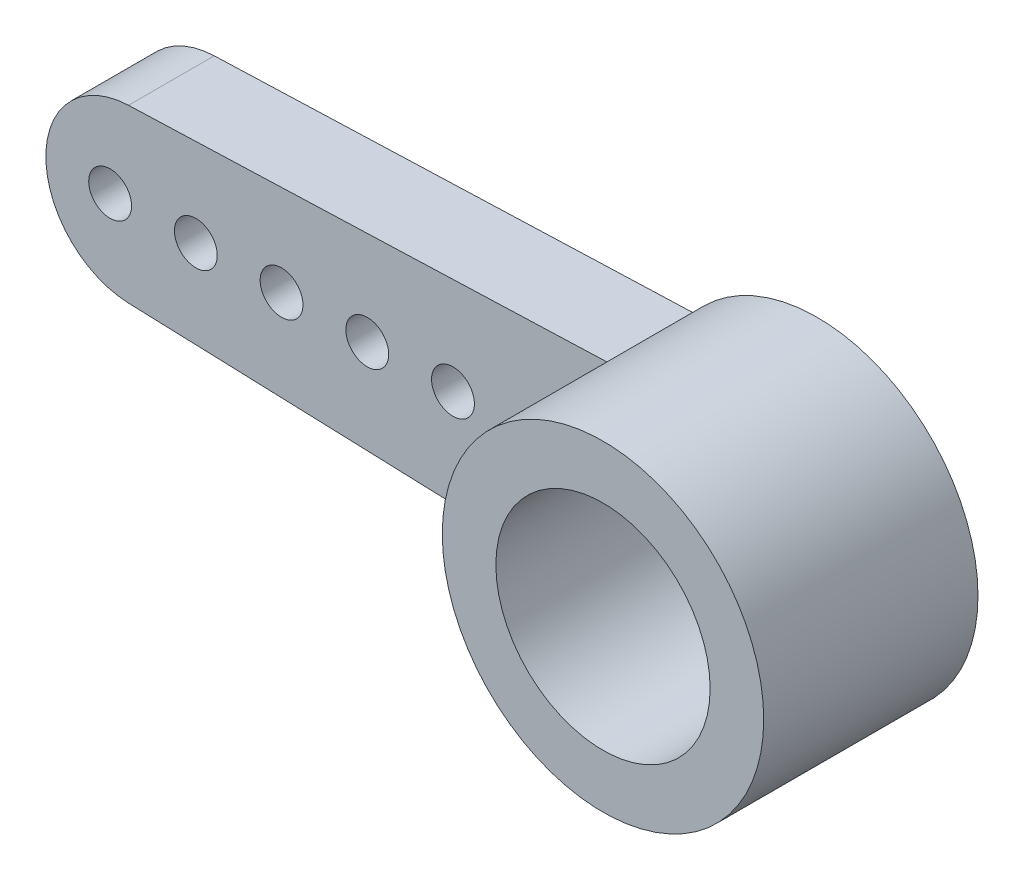
from build123d import *

# Parameters (mm, degrees)
EXTRUDE_3_DEPTH     = 2
EXTRUDE_3_2_DEPTH   = 2
SKETCH_2_R          = 3.75
SKETCH_2_R_2        = 2.5
EXTRUDE_5_DEPTH     = 3
SKETCH_3_R          = 3.75
SKETCH_3_R_2        = 2.5
EXTRUDE_6_DEPTH     = 2
SKETCH_4_R          = 0.5
CUT_EXTRUDE_1_DEPTH = 2
SKETCH_5_R          = 2.5
EXTRUDE_7_DEPTH     = 1
SKETCH_6_R          = 2.5
CUT_EXTRUDE_2_DEPTH = 0.5
SKETCH_7_R          = 1.25
CUT_EXTRUDE_3_DEPTH = 5
CUT_EXTRUDE1_DEPTH  = 6


with BuildPart() as part:
    # Эскиз1 → Бобышка-Вытянуть3 (new body)
    with BuildSketch(Plane.XY):
        with BuildLine():
            ThreePointArc((-2.885471, -2.395111), (-3.527252, -1.273182), (-3.75, 0))
            ThreePointArc((-3.75, 0), (-3.527252, 1.273182), (-2.885471, 2.395111))
            Line((-2.885471, 2.395111), (-14.070828, 1.998745))
            ThreePointArc((-14.070828, 1.998745), (-16, 0), (-14.070828, -1.998745))
            Line((-14.070828, -1.998745), (-2.885471, -2.395111))
        make_face()
    extrude(amount=EXTRUDE_3_DEPTH)



with BuildPart() as body_2:
    # Эскиз1 → Extrude 3 2 (new body)
    with BuildSketch(Plane.XY):
        with BuildLine():
            Line((14.070828, 1.998745), (2.885471, 2.395111))
            ThreePointArc((2.885471, 2.395111), (3.75, 0), (2.885471, -2.395111))
            Line((2.885471, -2.395111), (14.070828, -1.998745))
            ThreePointArc((14.070828, -1.998745), (16, 0), (14.070828, 1.998745))
        make_face()
    extrude(amount=EXTRUDE_3_2_DEPTH)


with BuildPart() as body_3:
    # Эскиз2 → Бобышка-Вытянуть5 (new body)
    with BuildSketch(Plane.XY.offset(2)):
        Circle(SKETCH_2_R)
        Circle(SKETCH_2_R_2, mode=Mode.SUBTRACT)
    extrude(amount=EXTRUDE_5_DEPTH)


with BuildPart() as part_1:
    add(part.part)

    add(body_2.part)  # Бобышка-Вытянуть6 merges body 2

    add(body_3.part)  # Бобышка-Вытянуть6 merges body 3
    # Эскиз3 → Бобышка-Вытянуть6 (add)
    with BuildSketch(Plane(origin=(0, 0, 2), x_dir=(-1, 0, 0), z_dir=(0, 0, -1))):
        Circle(SKETCH_3_R)
        Circle(SKETCH_3_R_2, mode=Mode.SUBTRACT)
    extrude(amount=EXTRUDE_6_DEPTH)

    # Эскиз4 → Вырез-Вытянуть1 (cut)
    with BuildSketch(Plane(origin=(0, 0, 0), x_dir=(-1, 0, 0), z_dir=(0, 0, -1))):
        with Locations((-14.5, 0)):
            Circle(SKETCH_4_R)
        with Locations((-4.5, 0)):
            Circle(SKETCH_4_R)
        with Locations((-6.5, 0)):
            Circle(SKETCH_4_R)
        with Locations((-8.5, 0)):
            Circle(SKETCH_4_R)
        with Locations((-10.5, 0)):
            Circle(SKETCH_4_R)
        with Locations((-12.5, 0)):
            Circle(SKETCH_4_R)
        with Locations((4.5, 0)):
            Circle(SKETCH_4_R)
        with Locations((6.5, 0)):
            Circle(SKETCH_4_R)
        with Locations((8.5, 0)):
            Circle(SKETCH_4_R)
        with Locations((10.5, 0)):
            Circle(SKETCH_4_R)
        with Locations((12.5, 0)):
            Circle(SKETCH_4_R)
        with Locations((14.5, 0)):
            Circle(SKETCH_4_R)
    extrude(amount=-CUT_EXTRUDE_1_DEPTH, mode=Mode.SUBTRACT)

    # Эскиз5 → Бобышка-Вытянуть7 (add)
    with BuildSketch(Plane(origin=(0, 0, 0), x_dir=(-1, 0, 0), z_dir=(0, 0, -1))):
        Circle(SKETCH_5_R)
    extrude(amount=-EXTRUDE_7_DEPTH)

    # Эскиз6 → Вырез-Вытянуть2 (cut)
    with BuildSketch(Plane(origin=(0, 0, 0), x_dir=(-1, 0, 0), z_dir=(0, 0, -1))):
        Circle(SKETCH_6_R)
    extrude(amount=-CUT_EXTRUDE_2_DEPTH, mode=Mode.SUBTRACT)

    # Эскиз7 → Вырез-Вытянуть3 (cut)
    with BuildSketch(Plane(origin=(0, 0, 0.5), x_dir=(-1, 0, 0), z_dir=(0, 0, -1))):
        Circle(SKETCH_7_R)
    extrude(amount=-CUT_EXTRUDE_3_DEPTH, mode=Mode.SUBTRACT)

    # Sketch1 → Cut-Extrude1 (cut, through all)
    with BuildSketch(Plane.XY.offset(5)):
        with BuildLine():
            ThreePointArc((3.75, 0), (3.527252, -1.273182), (2.885471, -2.395111))
            Line((2.885471, -2.395111), (14.070828, -1.998745))
            ThreePointArc((14.070828, -1.998745), (16, 0), (14.070828, 1.998745))
            Line((14.070828, 1.998745), (2.885471, 2.395111))
            ThreePointArc((2.885471, 2.395111), (3.527252, 1.273182), (3.75, 0))
        make_face()
    extrude(amount=-CUT_EXTRUDE1_DEPTH, mode=Mode.SUBTRACT)


solid = part_1.part
